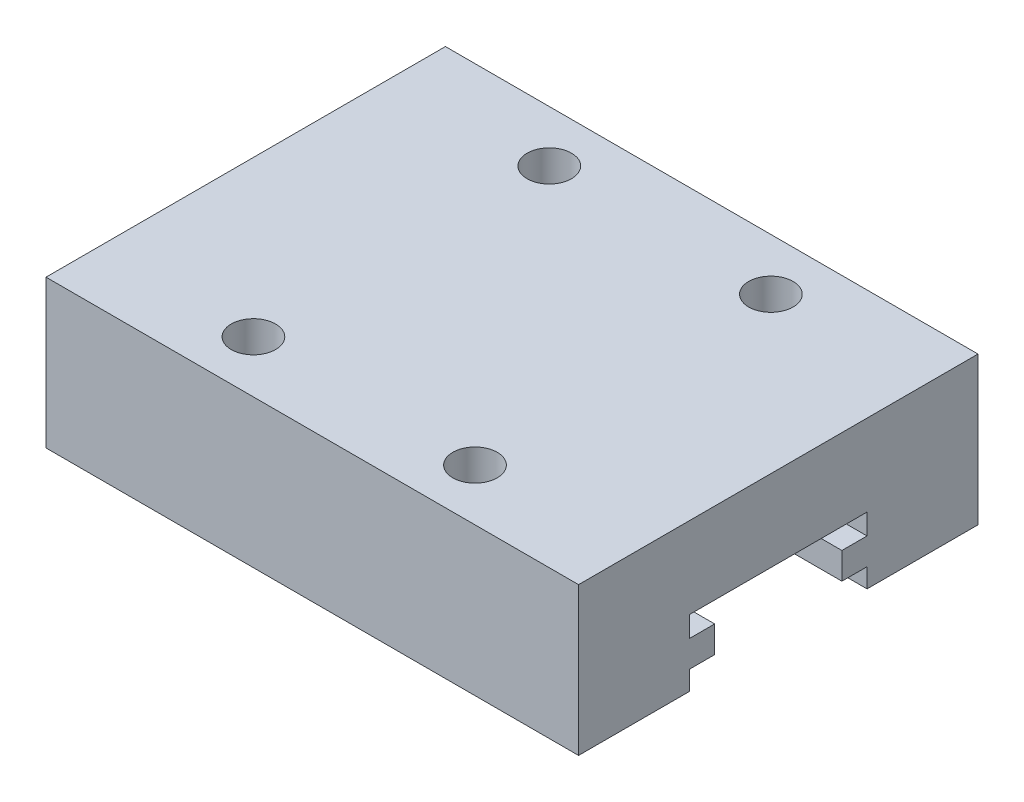
from build123d import *

# Parameters (mm, degrees)
CROQUIS1_W              = 36
CROQUIS1_H              = 27
SALIENTE_EXTRUIR1_DEPTH = 10
CROQUIS2_R              = 1.5
CORTAR_EXTRUIR1_DEPTH   = 5
CORTAR_EXTRUIR2_DEPTH   = 36


with BuildPart() as part:
    # Croquis1 → Saliente-Extruir1 (new body)
    with BuildSketch(Plane(origin=(0, 0, 0), x_dir=(1, 0, 0), z_dir=(0, 1, 0))):
        with Locations((18, 13.5)):
            Rectangle(CROQUIS1_W, CROQUIS1_H)
    extrude(amount=SALIENTE_EXTRUIR1_DEPTH)

    # Croquis2 → Cortar-Extruir1 (cut)
    with BuildSketch(Plane(origin=(0, 10, 0), x_dir=(1, 0, 0), z_dir=(0, 1, 0))):
        with Locations((10.5, 23.52014925)):
            Circle(CROQUIS2_R)
        with Locations((25.499986467, 23.5)):
            Circle(CROQUIS2_R)
        with Locations((10.5, 3.52014925)):
            Circle(CROQUIS2_R)
        with Locations((25.499986467, 3.5)):
            Circle(CROQUIS2_R)
    extrude(amount=-CORTAR_EXTRUIR1_DEPTH, mode=Mode.SUBTRACT)

    # Croquis3 → Cortar-Extruir2 (cut)
    with BuildSketch(Plane(origin=(36, 0, 0), x_dir=(0, 0, -1), z_dir=(1, 0, 0))):
        Polygon((7.5, 0), (19.5, 0), (19.5, 1.3), (17.8, 1.3), (17.8, 3.1), (19.5, 3.1), (19.5, 4.5), (7.5, 4.5), (7.5, 3.1), (9.2, 3.1), (9.2, 1.3), (7.5, 1.3), align=None)
    extrude(amount=-CORTAR_EXTRUIR2_DEPTH, mode=Mode.SUBTRACT)


solid = part.part
